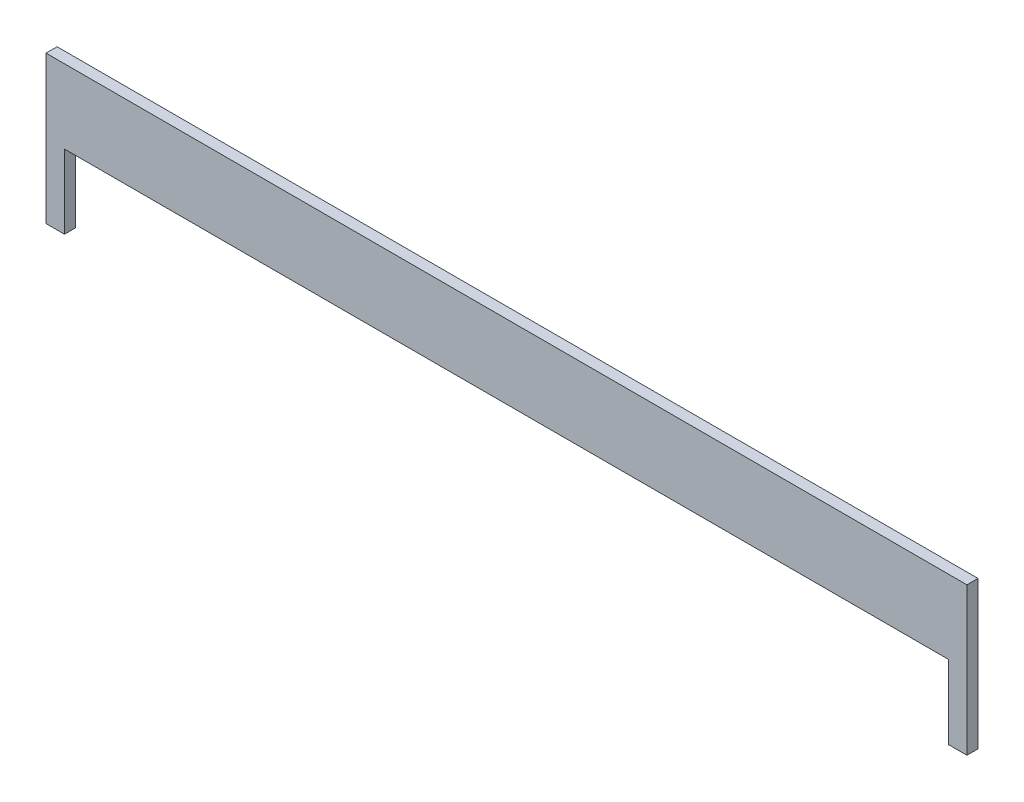
from build123d import *

# Parameters (mm, degrees)
SKETCH1_W           = 249.5
SKETCH1_H           = 40
BOSS_EXTRUDE1_DEPTH = 3
SKETCH2_W           = 239.5
SKETCH2_H           = 20
CUT_EXTRUDE1_DEPTH  = 5


with BuildPart() as part:
    # Sketch1 → Boss-Extrude1 (new body)
    with BuildSketch(Plane.XY):
        with Locations((124.75, -20)):
            Rectangle(SKETCH1_W, SKETCH1_H)
    extrude(amount=BOSS_EXTRUDE1_DEPTH)

    # Sketch2 → Cut-Extrude1 (cut)
    with BuildSketch(Plane.XY.offset(3)):
        with Locations((124.75, -30)):
            Rectangle(SKETCH2_W, SKETCH2_H)
    extrude(amount=-CUT_EXTRUDE1_DEPTH, mode=Mode.SUBTRACT)


solid = part.part
